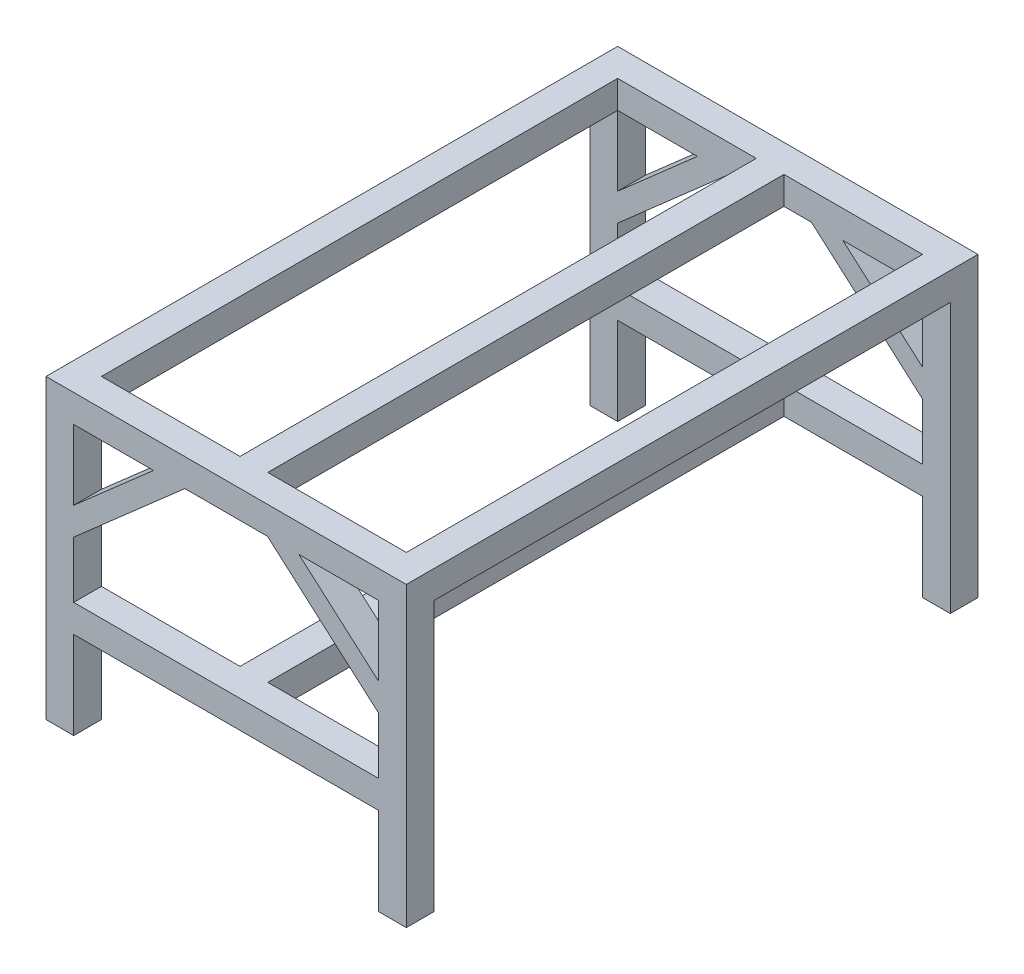
from build123d import *

# Parameters (mm, degrees)
BOSS_EXTRUDE1_DEPTH = 80
SKETCH2_W           = 80
SKETCH2_H           = 80
BOSS_EXTRUDE2_DEPTH = 790


with BuildPart() as part:
    # Sketch1 → Boss-Extrude1 (new body)
    with BuildSketch(Plane.XY):
        Polygon((1040, 0), (0, 0), (0, -857.8), (80, -857.8), (80, -604.8), (960, -604.8), (960, -857.8), (1040, -857.8), align=None)
        Polygon((960, -524.8), (80, -524.8), (80, -361.670887123), (400.767069293, -80), (639.232930707, -80), (960, -361.670887123), align=None, mode=Mode.SUBTRACT)
        Polygon((729.892680056, -80), (960, -80), (960, -282.061056595), align=None, mode=Mode.SUBTRACT)
        Polygon((80, -282.061056595), (80, -80), (310.107319944, -80), align=None, mode=Mode.SUBTRACT)
    boss_extrude1 = extrude(amount=-BOSS_EXTRUDE1_DEPTH)

    # Sketch2 → Boss-Extrude2 (add)
    with BuildSketch(Plane(origin=(0, 0, -80), x_dir=(-1, 0, 0), z_dir=(0, 0, -1))):
        with Locations((-1000, -40)):
            Rectangle(SKETCH2_W, SKETCH2_H)
        with Locations((-40, -40)):
            Rectangle(SKETCH2_W, SKETCH2_H)
        with Locations((-520, -564.8)):
            Rectangle(SKETCH2_W, SKETCH2_H)
        with Locations((-520, -40)):
            Rectangle(SKETCH2_W, SKETCH2_H)
    boss_extrude2 = extrude(amount=BOSS_EXTRUDE2_DEPTH)

    # Mirror2: Boss-Extrude2 across plane
    add(boss_extrude2.mirror(Plane.XY.offset(-825)))

    # Mirror3: Boss-Extrude1 across plane
    add(boss_extrude1.mirror(Plane.XY.offset(-825)))


solid = part.part
